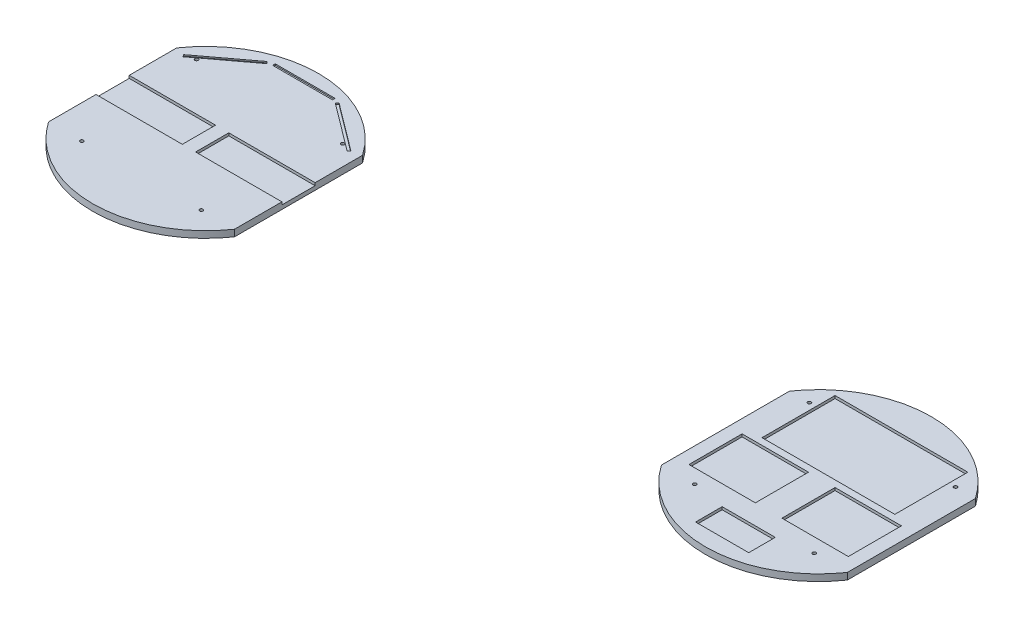
from build123d import *

# Parameters (mm, degrees)
BOSS_EXTRUDE4_DEPTH    = 4
SKETCH2_W              = 45
SKETCH2_H              = 2
BOSS_EXTRUDE4_2_DEPTH  = 4
BOSS_EXTRUDE4_3_DEPTH  = 4
SKETCH2_8_W            = 65
SKETCH2_8_H            = 25
BOSS_EXTRUDE5_DEPTH    = 3
BOSS_EXTRUDE5_2_DEPTH  = 3
SKETCH2_9_R            = 1.25
BOSS_EXTRUDE6_DEPTH    = 5
SKETCH2_14_W           = 100
SKETCH2_14_H           = 55
BOSS_EXTRUDE10_DEPTH   = 3
SKETCH2_14_W_2         = 50
SKETCH2_14_H_2         = 40
BOSS_EXTRUDE10_2_DEPTH = 3
BOSS_EXTRUDE10_3_DEPTH = 3
SKETCH2_14_W_3         = 40
SKETCH2_14_H_3         = 20
BOSS_EXTRUDE10_4_DEPTH = 3
SKETCH2_15_W           = 40
SKETCH2_15_H           = 20
SKETCH2_15_R           = 1.25
SKETCH2_15_W_2         = 50
SKETCH2_15_H_2         = 40
SKETCH2_15_W_3         = 100
SKETCH2_15_H_3         = 55
BOSS_EXTRUDE11_DEPTH   = 5


with BuildPart() as part:
    # Sketch2 → Boss-Extrude4 (new body)
    with BuildSketch(Plane(origin=(0, 0, 0), x_dir=(1, 0, 0), z_dir=(0, 1, 0))):
        Polygon((347.164253905, 49.026683577), (383.152150384, 76.042814073), (381.951433473, 77.642276139), (345.963536994, 50.626145642), align=None)
    extrude(amount=BOSS_EXTRUDE4_DEPTH)



with BuildPart() as body_2:
    # Sketch2 → Boss-Extrude4 2 (new body)
    with BuildSketch(Plane(origin=(0, 0, 0), x_dir=(1, 0, 0), z_dir=(0, 1, 0))):
        with Locations((408.984369394, 78.154383425)):
            Rectangle(SKETCH2_W, SKETCH2_H)
    extrude(amount=BOSS_EXTRUDE4_2_DEPTH)


with BuildPart() as body_3:
    # Sketch2 → Boss-Extrude4 3 (new body)
    with BuildSketch(Plane(origin=(0, 0, 0), x_dir=(1, 0, 0), z_dir=(0, 1, 0))):
        Polygon((471.626604108, 50.9103591), (436.017305315, 77.642276139), (434.816588404, 76.042814073), (470.425887197, 49.310897034), align=None)
    extrude(amount=BOSS_EXTRUDE4_3_DEPTH)


with BuildPart() as body_4:
    # Sketch2_8 → Boss-Extrude5 (new body)
    with BuildSketch(Plane(origin=(0, 0, 0), x_dir=(1, 0, 0), z_dir=(0, 1, 0))):
        with Locations((371.484369394, 4.154383425)):
            Rectangle(SKETCH2_8_W, SKETCH2_8_H)
    extrude(amount=BOSS_EXTRUDE5_DEPTH)


with BuildPart() as body_5:
    # Sketch2_8 → Boss-Extrude5 2 (new body)
    with BuildSketch(Plane(origin=(0, 0, 0), x_dir=(1, 0, 0), z_dir=(0, 1, 0))):
        with Locations((446.484369394, 4.154383425)):
            Rectangle(SKETCH2_8_W, SKETCH2_8_H)
    extrude(amount=BOSS_EXTRUDE5_2_DEPTH)


with BuildPart() as part_1:
    add(part.part)

    add(body_2.part)  # Boss-Extrude6 merges body 2

    add(body_3.part)  # Boss-Extrude6 merges body 3

    add(body_4.part)  # Boss-Extrude6 merges body 4

    add(body_5.part)  # Boss-Extrude6 merges body 5
    # Sketch2_9 → Boss-Extrude6 (add)
    with BuildSketch(Plane(origin=(0, 0, 0), x_dir=(1, 0, 0), z_dir=(0, 1, 0))):
        with BuildLine():
            ThreePointArc((408.984369394, 89.154383425), (382.086941195, 84.786438814), (357.953900679, 72.131521219))
            ThreePointArc((357.953900679, 72.131521219), (347.668001567, 63.021208008), (338.984369394, 52.37263723))
            Line((338.984369394, 52.37263723), (338.984369394, 16.654383425))
            Line((338.984369394, 16.654383425), (403.984369394, 16.654383425))
            Line((403.984369394, 16.654383425), (403.984369394, -8.345616575))
            Line((403.984369394, -8.345616575), (338.984369394, -8.345616575))
            Line((338.984369394, -8.345616575), (338.984369394, -44.06387038))
            ThreePointArc((338.984369394, -44.06387038), (408.984369394, -80.845616575), (478.984369394, -44.06387038))
            Line((478.984369394, -44.06387038), (478.984369394, -8.345616575))
            Line((478.984369394, -8.345616575), (413.984369394, -8.345616575))
            Line((413.984369394, -8.345616575), (413.984369394, 16.654383425))
            Line((413.984369394, 16.654383425), (478.984369394, 16.654383425))
            Line((478.984369394, 16.654383425), (478.984369394, 52.37263723))
            ThreePointArc((478.984369394, 52.37263723), (470.300737221, 63.021208008), (460.01483811, 72.131521219))
            ThreePointArc((460.01483811, 72.131521219), (435.881797594, 84.786438814), (408.984369394, 89.154383425))
        make_face()
        with Locations((363.984369394, -44.06387038)):
            Circle(SKETCH2_9_R, mode=Mode.SUBTRACT)
        with Locations((453.984369394, -44.06387038)):
            Circle(SKETCH2_9_R, mode=Mode.SUBTRACT)
        with Locations((353.984369394, 52.37263723)):
            Circle(SKETCH2_9_R, mode=Mode.SUBTRACT)
        Polygon((345.963536994, 50.626145642), (363.957485234, 64.134210891), (381.951433473, 77.642276139), (383.152150384, 76.042814073), (365.158202144, 62.534748825), (347.164253905, 49.026683577), align=None, mode=Mode.SUBTRACT)
        Polygon((386.484369394, 79.154383425), (408.984369394, 79.154383425), (431.484369394, 79.154383425), (431.484369394, 77.154383425), (408.984369394, 77.154383425), (386.484369394, 77.154383425), align=None, mode=Mode.SUBTRACT)
        with Locations((463.984369394, 52.37263723)):
            Circle(SKETCH2_9_R, mode=Mode.SUBTRACT)
        Polygon((436.017305315, 77.642276139), (454.011253555, 64.134210891), (471.626604108, 50.9103591), (470.425887197, 49.310897034), (452.810536644, 62.534748825), (434.816588404, 76.042814073), align=None, mode=Mode.SUBTRACT)
    extrude(amount=BOSS_EXTRUDE6_DEPTH)


with BuildPart() as body_2_2:
    # Sketch2_14 → Boss-Extrude10 (new body)
    with BuildSketch(Plane(origin=(0, 0, 0), x_dir=(1, 0, 0), z_dir=(0, 1, 0))):
        with Locations((863.509082659, 46.099585356)):
            Rectangle(SKETCH2_14_W, SKETCH2_14_H)
    extrude(amount=BOSS_EXTRUDE10_DEPTH)



with BuildPart() as body_3_2:
    # Sketch2_14 → Boss-Extrude10 2 (new body)
    with BuildSketch(Plane(origin=(0, 0, 0), x_dir=(1, 0, 0), z_dir=(0, 1, 0))):
        with Locations((898.509082659, -6.400414644)):
            Rectangle(SKETCH2_14_W_2, SKETCH2_14_H_2)
    extrude(amount=BOSS_EXTRUDE10_2_DEPTH)


with BuildPart() as body_4_2:
    # Sketch2_14 → Boss-Extrude10 3 (new body)
    with BuildSketch(Plane(origin=(0, 0, 0), x_dir=(1, 0, 0), z_dir=(0, 1, 0))):
        with Locations((828.509082659, -6.400414644)):
            Rectangle(SKETCH2_14_W_2, SKETCH2_14_H_2)
    extrude(amount=BOSS_EXTRUDE10_3_DEPTH)


with BuildPart() as body_5_2:
    # Sketch2_14 → Boss-Extrude10 4 (new body)
    with BuildSketch(Plane(origin=(0, 0, 0), x_dir=(1, 0, 0), z_dir=(0, 1, 0))):
        with Locations((863.509082659, -51.400414644)):
            Rectangle(SKETCH2_14_W_3, SKETCH2_14_H_3)
    extrude(amount=BOSS_EXTRUDE10_4_DEPTH)


with BuildPart() as body_2_2_1:
    add(body_2_2.part)

    add(body_3_2.part)  # Boss-Extrude11 merges body 3 2

    add(body_4_2.part)  # Boss-Extrude11 merges body 4 2

    add(body_5_2.part)  # Boss-Extrude11 merges body 5 2
    # Sketch2_15 → Boss-Extrude11 (add)
    with BuildSketch(Plane(origin=(0, 0, 0), x_dir=(1, 0, 0), z_dir=(0, 1, 0))):
        with BuildLine():
            ThreePointArc((793.509082659, -37.118668449), (863.509082659, -73.900414644), (933.509082659, -37.118668449))
            Line((933.509082659, -37.118668449), (933.509082659, 59.31783916))
            ThreePointArc((933.509082659, 59.31783916), (863.509082659, 96.099585356), (793.509082659, 59.31783916))
            Line((793.509082659, 59.31783916), (793.509082659, -37.118668449))
        make_face()
        with Locations((863.509082659, -51.400414644)):
            Rectangle(SKETCH2_15_W, SKETCH2_15_H, mode=Mode.SUBTRACT)
        with Locations((818.509082659, -37.118668449)):
            Circle(SKETCH2_15_R, mode=Mode.SUBTRACT)
        with Locations((908.509082659, -37.118668449)):
            Circle(SKETCH2_15_R, mode=Mode.SUBTRACT)
        with Locations((828.509082659, -6.400414644)):
            Rectangle(SKETCH2_15_W_2, SKETCH2_15_H_2, mode=Mode.SUBTRACT)
        with Locations((898.509082659, -6.400414644)):
            Rectangle(SKETCH2_15_W_2, SKETCH2_15_H_2, mode=Mode.SUBTRACT)
        with Locations((863.509082659, 46.099585356)):
            Rectangle(SKETCH2_15_W_3, SKETCH2_15_H_3, mode=Mode.SUBTRACT)
        with Locations((808.509082659, 59.31783916)):
            Circle(SKETCH2_15_R, mode=Mode.SUBTRACT)
        with Locations((918.509082659, 59.31783916)):
            Circle(SKETCH2_15_R, mode=Mode.SUBTRACT)
    extrude(amount=BOSS_EXTRUDE11_DEPTH)


solid = Compound([part_1.part, body_2_2_1.part])
